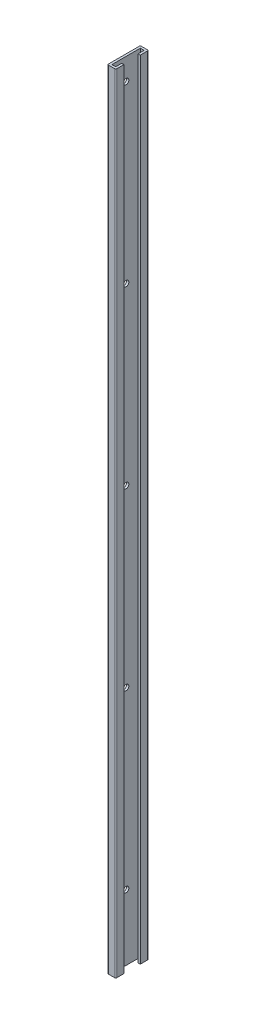
from build123d import *

# Parameters (mm, degrees)
BOSS_EXTRUDE1_DEPTH = 914.4
CUT_EXTRUDE1_REACH  = 4.54
SKETCH2_R           = 3.175


with BuildPart() as part:
    # Sketch1 → Boss-Extrude1 (new body)
    with BuildSketch(Plane(origin=(0, 0, 0), x_dir=(1, 0, 0), z_dir=(0, 1, 0))):
        with BuildLine():
            Line((9.525, 34.29), (9.525, 26.035))
            Line((9.525, 26.035), (6.985, 26.035))
            Line((6.985, 26.035), (6.985, 33.02))
            Line((6.985, 33.02), (2.54, 33.02))
            Line((2.54, 33.02), (2.54, 0))
            Line((2.54, 0), (6.985, 0))
            Line((6.985, 0), (6.985, 6.985))
            Line((6.985, 6.985), (9.525, 6.985))
            Line((9.525, 6.985), (9.525, -1.27))
            ThreePointArc((9.525, -1.27), (9.153025612, -2.168025612), (8.255, -2.54))
            Line((8.255, -2.54), (1.27, -2.54))
            ThreePointArc((1.27, -2.54), (0.371974388, -2.168025612), (0, -1.27))
            Line((0, -1.27), (0, 34.29))
            ThreePointArc((0, 34.29), (0.371974388, 35.188025612), (1.27, 35.56))
            Line((1.27, 35.56), (8.255, 35.56))
            ThreePointArc((8.255, 35.56), (9.153025612, 35.188025612), (9.525, 34.29))
        make_face()
    extrude(amount=BOSS_EXTRUDE1_DEPTH)

    # Sketch2 → Cut-Extrude1 (cut, up to next)
    with BuildSketch(Plane(origin=(2.54, 0, 0), x_dir=(0, 0, -1), z_dir=(1, 0, 0)), mode=Mode.PRIVATE) as cut_extrude1_sk1:
        with Locations((16.51, 76.2)):
            Circle(SKETCH2_R)
    cut_extrude1_tool1 = extrude(cut_extrude1_sk1.sketch, amount=-CUT_EXTRUDE1_REACH, mode=Mode.PRIVATE) & part.part
    add(cut_extrude1_tool1.solids().sort_by_distance((2.54, 76.2, -16.51))[0], mode=Mode.SUBTRACT)
    # Sketch2 → Cut-Extrude1 (cut, up to next)
    with BuildSketch(Plane(origin=(2.54, 0, 0), x_dir=(0, 0, -1), z_dir=(1, 0, 0)), mode=Mode.PRIVATE) as cut_extrude1_sk2:
        with Locations((16.51, 279.4)):
            Circle(SKETCH2_R)
    cut_extrude1_tool2 = extrude(cut_extrude1_sk2.sketch, amount=-CUT_EXTRUDE1_REACH, mode=Mode.PRIVATE) & part.part
    add(cut_extrude1_tool2.solids().sort_by_distance((2.54, 279.4, -16.51))[0], mode=Mode.SUBTRACT)
    # Sketch2 → Cut-Extrude1 (cut, up to next)
    with BuildSketch(Plane(origin=(2.54, 0, 0), x_dir=(0, 0, -1), z_dir=(1, 0, 0)), mode=Mode.PRIVATE) as cut_extrude1_sk3:
        with Locations((16.51, 482.6)):
            Circle(SKETCH2_R)
    cut_extrude1_tool3 = extrude(cut_extrude1_sk3.sketch, amount=-CUT_EXTRUDE1_REACH, mode=Mode.PRIVATE) & part.part
    add(cut_extrude1_tool3.solids().sort_by_distance((2.54, 482.6, -16.51))[0], mode=Mode.SUBTRACT)
    # Sketch2 → Cut-Extrude1 (cut, up to next)
    with BuildSketch(Plane(origin=(2.54, 0, 0), x_dir=(0, 0, -1), z_dir=(1, 0, 0)), mode=Mode.PRIVATE) as cut_extrude1_sk4:
        with Locations((16.51, 685.8)):
            Circle(SKETCH2_R)
    cut_extrude1_tool4 = extrude(cut_extrude1_sk4.sketch, amount=-CUT_EXTRUDE1_REACH, mode=Mode.PRIVATE) & part.part
    add(cut_extrude1_tool4.solids().sort_by_distance((2.54, 685.8, -16.51))[0], mode=Mode.SUBTRACT)
    # Sketch2 → Cut-Extrude1 (cut, up to next)
    with BuildSketch(Plane(origin=(2.54, 0, 0), x_dir=(0, 0, -1), z_dir=(1, 0, 0)), mode=Mode.PRIVATE) as cut_extrude1_sk5:
        with Locations((16.51, 889)):
            Circle(SKETCH2_R)
    cut_extrude1_tool5 = extrude(cut_extrude1_sk5.sketch, amount=-CUT_EXTRUDE1_REACH, mode=Mode.PRIVATE) & part.part
    add(cut_extrude1_tool5.solids().sort_by_distance((2.54, 889, -16.51))[0], mode=Mode.SUBTRACT)


solid = part.part
